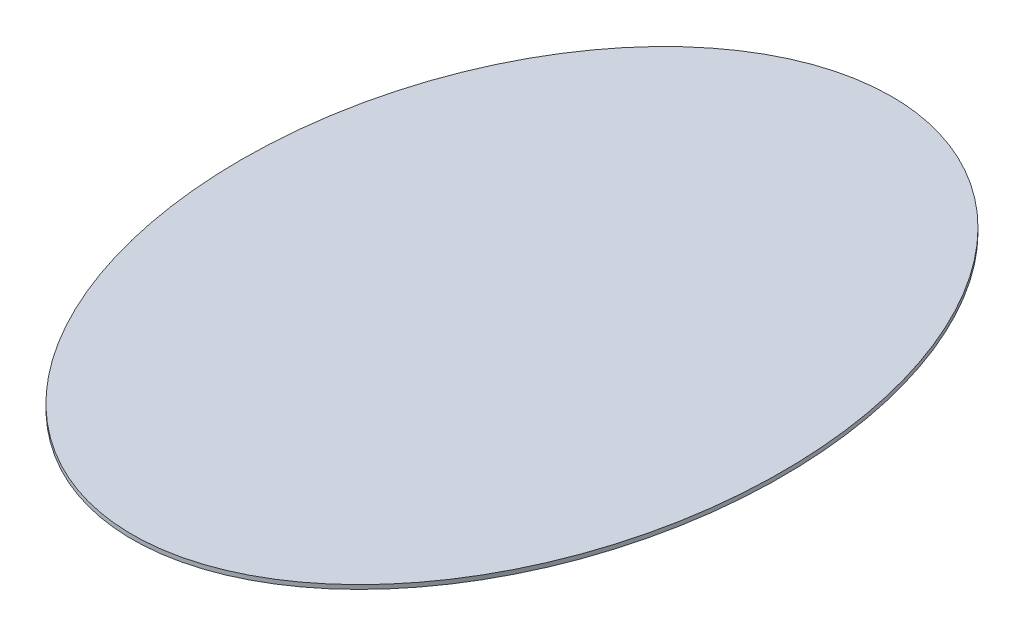
from build123d import *

# Parameters (mm, degrees)
SKETCH1_RX          = 365
SKETCH1_RY          = 260
BOSS_EXTRUDE1_DEPTH = 4


with BuildPart() as part:
    # Sketch1 → Boss-Extrude1 (new body)
    with BuildSketch(Plane(origin=(0, 0, 0), x_dir=(1, 0, 0), z_dir=(0, 1, 0))):
        with Locations(Location((0, 0), (0, 0, 90))):
            Ellipse(SKETCH1_RX, SKETCH1_RY)
    extrude(amount=BOSS_EXTRUDE1_DEPTH)


solid = part.part
